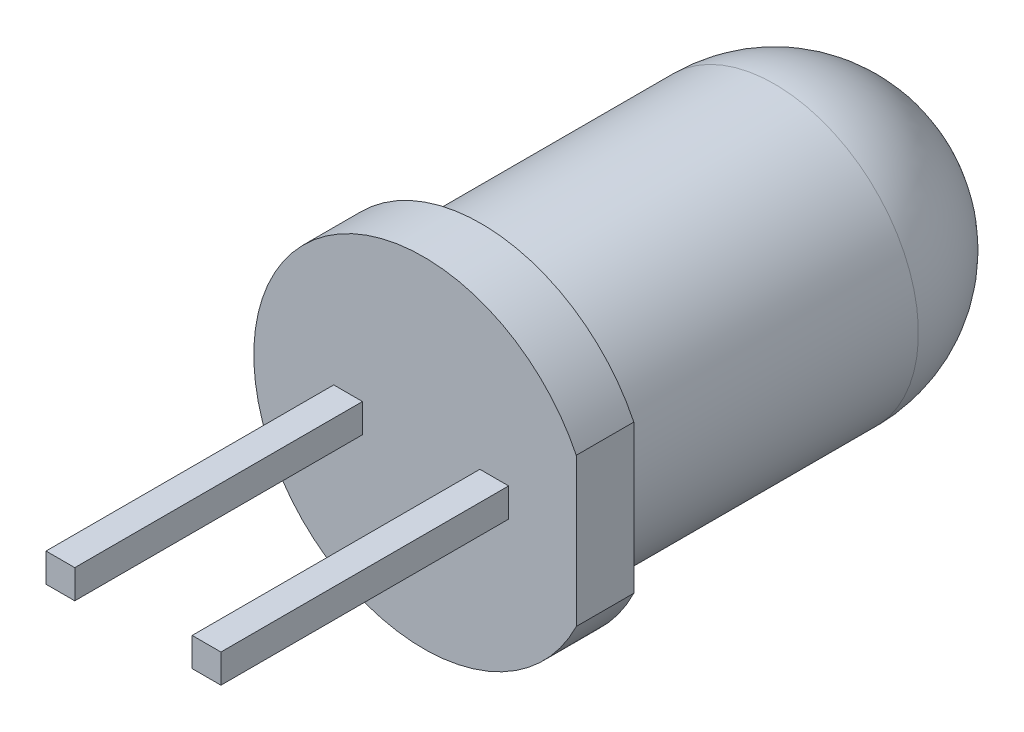
from build123d import *

# Parameters (mm, degrees)
SKETCH2_W           = 0.5
SKETCH2_H           = 0.5
BOSS_EXTRUDE1_DEPTH = 5
CUT_EXTRUDE1_REACH  = 10.6


with BuildPart() as part:
    # Sketch1 → Revolve3 (revolve)
    with BuildSketch(Plane(origin=(0, 0, 0), x_dir=(1, 0, 0), z_dir=(0, 1, 0))):
        with BuildLine():
            Line((0.041424419, -1.31875), (-2.908575581, -1.31875))
            Line((-2.908575581, -1.31875), (-2.908575581, -0.31875))
            Line((-2.908575581, -0.31875), (-2.458575581, -0.31875))
            Line((-2.458575581, -0.31875), (-2.458575581, 4.78125))
            ThreePointArc((-2.458575581, 4.78125), (-1.726342534, 6.549016953), (0.041424419, 7.28125))
            Line((0.041424419, 7.28125), (0.041424419, 6.960699472))
            Line((0.041424419, 6.960699472), (-0.258575581, 6.960699472))
            ThreePointArc((-0.258575581, 6.960699472), (-1.616887977, 6.226933229), (-2.158575581, 4.78125))
            Line((-2.158575581, 4.78125), (-2.158575581, -0.61875))
            Line((-2.158575581, -0.61875), (-2.608575581, -0.61875))
            Line((-2.608575581, -0.61875), (-2.608575581, -1.01875))
            Line((-2.608575581, -1.01875), (-0.258575581, -1.01875))
            Line((-0.258575581, -1.01875), (0.041424419, -1.01875))
            Line((0.041424419, -1.01875), (0.041424419, -1.31875))
        make_face()
    revolve(axis=Axis((0.041424419, 0, -7.28125), (0, 0, 1)))

    # Sketch2 → Boss-Extrude1 (add)
    with BuildSketch(Plane.XY.offset(1.31875)):
        with Locations((1.27, -0.01024953)):
            Rectangle(SKETCH2_W, SKETCH2_H)
        with Locations((-1.27, -0.01024953)):
            Rectangle(SKETCH2_W, SKETCH2_H)
    extrude(amount=BOSS_EXTRUDE1_DEPTH)

    # Sketch3 → Cut-Extrude1 (cut, up to next)
    with BuildSketch(Plane(origin=(0.020061741, 0, 1.31875), x_dir=(1, 0, 0), z_dir=(0, 0, 1)), mode=Mode.PRIVATE) as cut_extrude1_sk1:
        Polygon((2.675232006, 2.192680339), (2.675232006, -2.268878516), (4.29481628, -2.502381421), (4.160489908, 2.299424082), align=None)
    cut_extrude1_tool1 = extrude(cut_extrude1_sk1.sketch, amount=-CUT_EXTRUDE1_REACH, mode=Mode.PRIVATE) & part.part
    add(cut_extrude1_tool1.solids().sort_by_distance((3.481327, -0.10236, 1.31875))[0], mode=Mode.SUBTRACT)


solid = part.part
